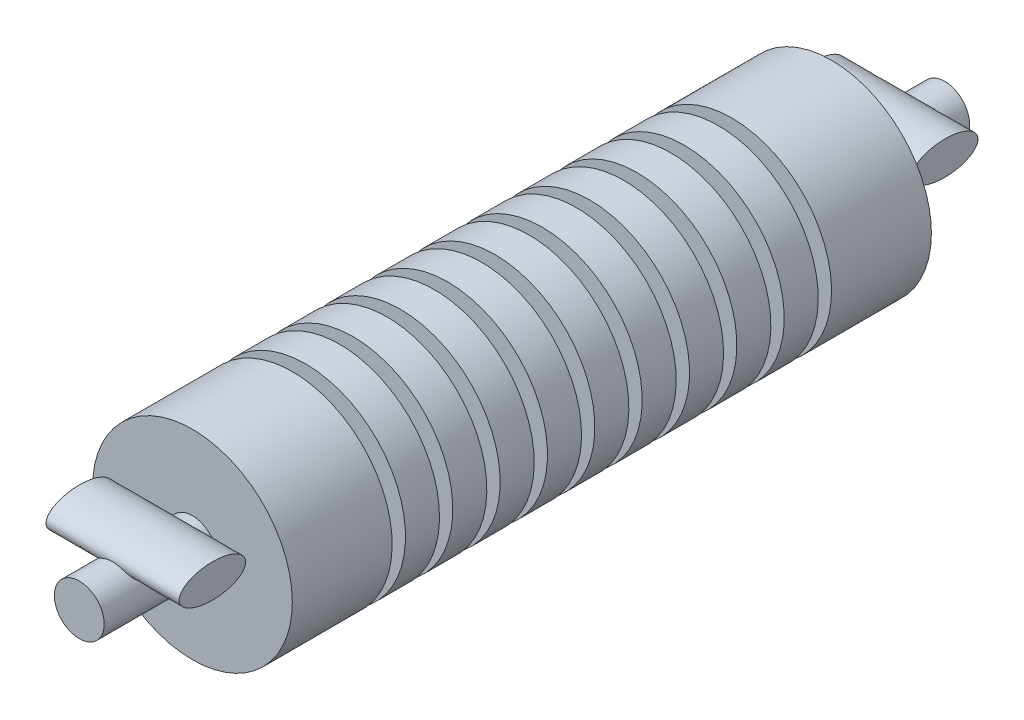
from build123d import *

# Parameters (mm, degrees)
SKETCH1_R               = 1.5
BOSS_EXTRUDE1_DEPTH     = 4.8
SKETCH2_W               = 0.2
SKETCH2_H               = 3
CUT_EXTRUDE1_DEPTH      = 2.5
CUT_EXTRUDE1_DEPTH_BACK = 2.5
SKETCH3_R               = 0.375
BOSS_EXTRUDE2_DEPTH     = 6.5
SKETCH4_RX              = 0.5
SKETCH4_RY              = 0.25
BOSS_EXTRUDE3_DEPTH     = 1


with BuildPart() as part:
    # Sketch1 → Boss-Extrude1 (new body, symmetric)
    with BuildSketch(Plane.XY):
        Circle(SKETCH1_R)
    extrude(amount=BOSS_EXTRUDE1_DEPTH, both=True)

    # Sketch2 → Cut-Extrude1 (cut, two sides)
    with BuildSketch(Plane(origin=(0, 0, 0), x_dir=(0, 0, -1), z_dir=(1, 0, 0))) as cut_extrude1_sk:
        with Locations((-3.2, 0)):
            Rectangle(SKETCH2_W, SKETCH2_H)
        with Locations((-2.488888889, 0)):
            Rectangle(SKETCH2_W, SKETCH2_H)
        with Locations((-1.777777778, 0)):
            Rectangle(SKETCH2_W, SKETCH2_H)
        with Locations((-1.066666667, 0)):
            Rectangle(SKETCH2_W, SKETCH2_H)
        with Locations((-0.355555556, 0)):
            Rectangle(SKETCH2_W, SKETCH2_H)
        with Locations((0.355555556, 0)):
            Rectangle(SKETCH2_W, SKETCH2_H)
        with Locations((1.066666667, 0)):
            Rectangle(SKETCH2_W, SKETCH2_H)
        with Locations((1.777777778, 0)):
            Rectangle(SKETCH2_W, SKETCH2_H)
        with Locations((2.488888889, 0)):
            Rectangle(SKETCH2_W, SKETCH2_H)
        with Locations((3.2, 0)):
            Rectangle(SKETCH2_W, SKETCH2_H)
    extrude(amount=CUT_EXTRUDE1_DEPTH, mode=Mode.SUBTRACT)
    extrude(cut_extrude1_sk.sketch, amount=-CUT_EXTRUDE1_DEPTH_BACK, mode=Mode.SUBTRACT)

    # Sketch3 → Boss-Extrude2 (add, symmetric)
    with BuildSketch(Plane.XY):
        Circle(SKETCH3_R)
    extrude(amount=BOSS_EXTRUDE2_DEPTH, both=True)

    # Sketch4 → Boss-Extrude3 (add, symmetric)
    with BuildSketch(Plane(origin=(0, 0, 0), x_dir=(0, 0, -1), z_dir=(1, 0, 0))):
        with Locations((-5.5, 0.375)):
            Ellipse(SKETCH4_RX, SKETCH4_RY)
        with Locations(Location((5.5, 0.375), (0, 0, 180))):
            Ellipse(SKETCH4_RX, SKETCH4_RY)
    extrude(amount=BOSS_EXTRUDE3_DEPTH, both=True)


solid = part.part
